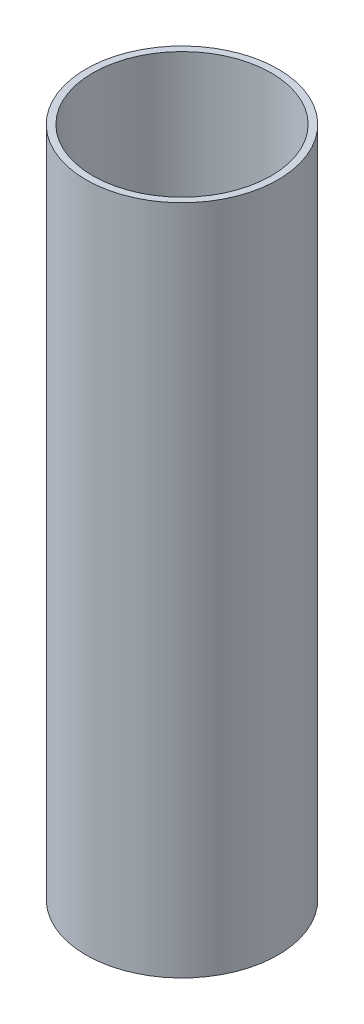
from build123d import *

# Parameters (mm, degrees)
SKETCH1_W = 1.8034
SKETCH1_H = 177.8


with BuildPart() as part:
    # Sketch1 → Revolve1 (revolve)
    with BuildSketch(Plane.XY):
        with Locations((24.5237, 88.9)):
            Rectangle(SKETCH1_W, SKETCH1_H)
    revolve(axis=Axis((0, -13.97, 0), (0, 1, 0)))


solid = part.part
